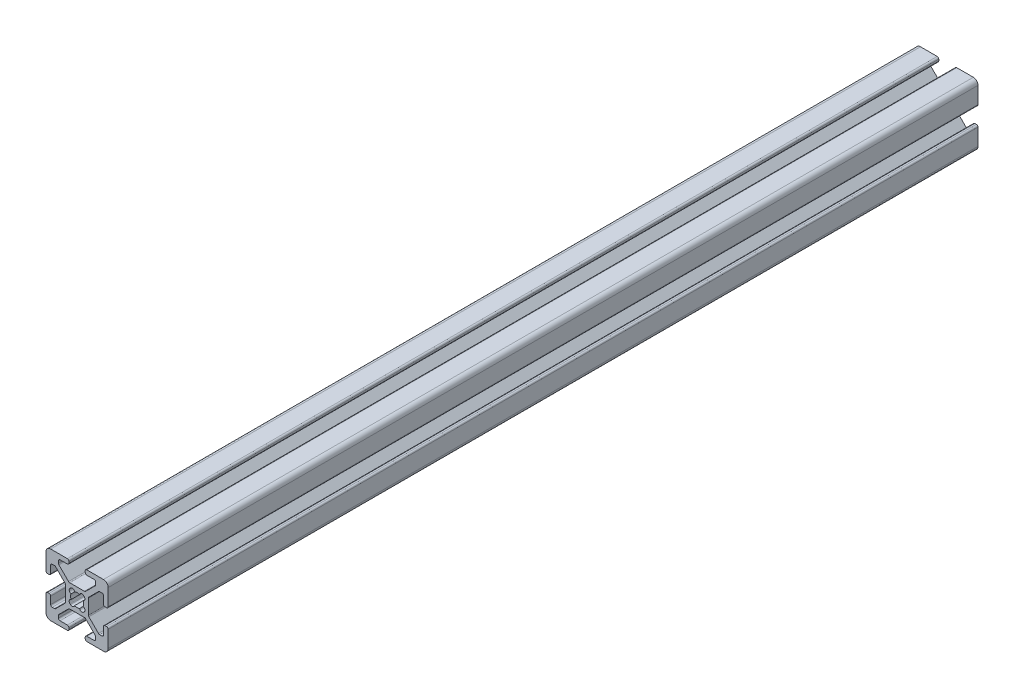
from build123d import *

# Parameters (mm, degrees)
BOSS_EXTRUDE1_DEPTH = 280


with BuildPart() as part:
    # Sketch1 → Boss-Extrude1 (new body)
    with BuildSketch(Plane.XY.offset(4000)):
        with BuildLine():
            Line((10, 3.138), (10, 8.5))
            ThreePointArc((10, 8.5), (9.560660172, 9.560660172), (8.5, 10))
            Line((8.5, 10), (3.138, 10))
            ThreePointArc((3.138, 10), (2.778789755, 9.851210245), (2.63, 9.492))
            Line((2.63, 9.492), (2.63, 9.008))
            ThreePointArc((2.63, 9.008), (2.778789755, 8.648789755), (3.138, 8.5))
            Line((3.138, 8.5), (5.487, 8.5))
            ThreePointArc((5.487, 8.5), (5.846210245, 8.351210245), (5.995, 7.992))
            Line((5.995, 7.992), (5.995, 7.266080661))
            ThreePointArc((5.995, 7.266080661), (5.956330803, 7.071677478), (5.846210245, 6.906870417))
            Line((5.846210245, 6.906870417), (2.743129583, 3.803789755))
            ThreePointArc((2.743129583, 3.803789755), (2.578322522, 3.693669197), (2.383919339, 3.655))
            Line((2.383919339, 3.655), (-2.383919339, 3.655))
            ThreePointArc((-2.383919339, 3.655), (-2.578322522, 3.693669197), (-2.743129583, 3.803789755))
            Line((-2.743129583, 3.803789755), (-5.846210245, 6.906870417))
            ThreePointArc((-5.846210245, 6.906870417), (-5.956330803, 7.071677478), (-5.995, 7.266080661))
            Line((-5.995, 7.266080661), (-5.995, 7.992))
            ThreePointArc((-5.995, 7.992), (-5.846210245, 8.351210245), (-5.487, 8.5))
            Line((-5.487, 8.5), (-3.138, 8.5))
            ThreePointArc((-3.138, 8.5), (-2.778789755, 8.648789755), (-2.63, 9.008))
            Line((-2.63, 9.008), (-2.63, 9.492))
            ThreePointArc((-2.63, 9.492), (-2.778789755, 9.851210245), (-3.138, 10))
            Line((-3.138, 10), (-8.5, 10))
            ThreePointArc((-8.5, 10), (-9.560660172, 9.560660172), (-10, 8.5))
            Line((-10, 8.5), (-10, 3.138))
            ThreePointArc((-10, 3.138), (-9.851210245, 2.778789755), (-9.492, 2.63))
            Line((-9.492, 2.63), (-9.008, 2.63))
            ThreePointArc((-9.008, 2.63), (-8.648789755, 2.778789755), (-8.5, 3.138))
            Line((-8.5, 3.138), (-8.5, 5.487))
            ThreePointArc((-8.5, 5.487), (-8.351210245, 5.846210245), (-7.992, 5.995))
            Line((-7.992, 5.995), (-7.266080661, 5.995))
            ThreePointArc((-7.266080661, 5.995), (-7.071677478, 5.956330803), (-6.906870417, 5.846210245))
            Line((-6.906870417, 5.846210245), (-3.803789755, 2.743129583))
            ThreePointArc((-3.803789755, 2.743129583), (-3.693669197, 2.578322522), (-3.655, 2.383919339))
            Line((-3.655, 2.383919339), (-3.655, -2.383919339))
            ThreePointArc((-3.655, -2.383919339), (-3.693669197, -2.578322522), (-3.803789755, -2.743129583))
            Line((-3.803789755, -2.743129583), (-6.906870417, -5.846210245))
            ThreePointArc((-6.906870417, -5.846210245), (-7.071677478, -5.956330803), (-7.266080661, -5.995))
            Line((-7.266080661, -5.995), (-7.992, -5.995))
            ThreePointArc((-7.992, -5.995), (-8.351210245, -5.846210245), (-8.5, -5.487))
            Line((-8.5, -5.487), (-8.5, -3.138))
            ThreePointArc((-8.5, -3.138), (-8.648789755, -2.778789755), (-9.008, -2.63))
            Line((-9.008, -2.63), (-9.492, -2.63))
            ThreePointArc((-9.492, -2.63), (-9.851210245, -2.778789755), (-10, -3.138))
            Line((-10, -3.138), (-10, -8.5))
            ThreePointArc((-10, -8.5), (-9.560660172, -9.560660172), (-8.5, -10))
            Line((-8.5, -10), (-3.138, -10))
            ThreePointArc((-3.138, -10), (-2.778789755, -9.851210245), (-2.63, -9.492))
            Line((-2.63, -9.492), (-2.63, -9.008))
            ThreePointArc((-2.63, -9.008), (-2.778789755, -8.648789755), (-3.138, -8.5))
            Line((-3.138, -8.5), (-5.487, -8.5))
            ThreePointArc((-5.487, -8.5), (-5.846210245, -8.351210245), (-5.995, -7.992))
            Line((-5.995, -7.992), (-5.995, -7.266080661))
            ThreePointArc((-5.995, -7.266080661), (-5.956330803, -7.071677478), (-5.846210245, -6.906870417))
            Line((-5.846210245, -6.906870417), (-2.743129583, -3.803789755))
            ThreePointArc((-2.743129583, -3.803789755), (-2.578322522, -3.693669197), (-2.383919339, -3.655))
            Line((-2.383919339, -3.655), (2.383919339, -3.655))
            ThreePointArc((2.383919339, -3.655), (2.578322522, -3.693669197), (2.743129583, -3.803789755))
            Line((2.743129583, -3.803789755), (5.846210245, -6.906870417))
            ThreePointArc((5.846210245, -6.906870417), (5.956330803, -7.071677478), (5.995, -7.266080661))
            Line((5.995, -7.266080661), (5.995, -7.992))
            ThreePointArc((5.995, -7.992), (5.846210245, -8.351210245), (5.487, -8.5))
            Line((5.487, -8.5), (3.138, -8.5))
            ThreePointArc((3.138, -8.5), (2.778789755, -8.648789755), (2.63, -9.008))
            Line((2.63, -9.008), (2.63, -9.492))
            ThreePointArc((2.63, -9.492), (2.778789755, -9.851210245), (3.138, -10))
            Line((3.138, -10), (8.5, -10))
            ThreePointArc((8.5, -10), (9.560660172, -9.560660172), (10, -8.5))
            Line((10, -8.5), (10, -3.138))
            ThreePointArc((10, -3.138), (9.851210245, -2.778789755), (9.492, -2.63))
            Line((9.492, -2.63), (9.008, -2.63))
            ThreePointArc((9.008, -2.63), (8.648789755, -2.778789755), (8.5, -3.138))
            Line((8.5, -3.138), (8.5, -5.487))
            ThreePointArc((8.5, -5.487), (8.351210245, -5.846210245), (7.992, -5.995))
            Line((7.992, -5.995), (7.266080661, -5.995))
            ThreePointArc((7.266080661, -5.995), (7.071677478, -5.956330803), (6.906870417, -5.846210245))
            Line((6.906870417, -5.846210245), (3.803789755, -2.743129583))
            ThreePointArc((3.803789755, -2.743129583), (3.693669197, -2.578322522), (3.655, -2.383919339))
            Line((3.655, -2.383919339), (3.655, 2.383919339))
            ThreePointArc((3.655, 2.383919339), (3.693669197, 2.578322522), (3.803789755, 2.743129583))
            Line((3.803789755, 2.743129583), (6.906870417, 5.846210245))
            ThreePointArc((6.906870417, 5.846210245), (7.071677478, 5.956330803), (7.266080661, 5.995))
            Line((7.266080661, 5.995), (7.992, 5.995))
            ThreePointArc((7.992, 5.995), (8.351210245, 5.846210245), (8.5, 5.487))
            Line((8.5, 5.487), (8.5, 3.138))
            ThreePointArc((8.5, 3.138), (8.648789755, 2.778789755), (9.008, 2.63))
            Line((9.008, 2.63), (9.492, 2.63))
            ThreePointArc((9.492, 2.63), (9.851210245, 2.778789755), (10, 3.138))
        make_face()
        with BuildLine():
            Line((-2.124900844, -2.304505966), (-2.304505966, -2.124900844))
            ThreePointArc((-2.304505966, -2.124900844), (-2.505938017, -1.356467811), (-1.935133506, -0.803976718))
            ThreePointArc((-1.935133506, -0.803976718), (-2.0955, 0), (-1.935133506, 0.803976718))
            ThreePointArc((-1.935133506, 0.803976718), (-2.505938017, 1.356467811), (-2.304505966, 2.124900844))
            Line((-2.304505966, 2.124900844), (-2.124900844, 2.304505966))
            ThreePointArc((-2.124900844, 2.304505966), (-1.356467811, 2.505938017), (-0.803976718, 1.935133506))
            ThreePointArc((-0.803976718, 1.935133506), (0, 2.0955), (0.803976718, 1.935133506))
            ThreePointArc((0.803976718, 1.935133506), (1.356467811, 2.505938017), (2.124900844, 2.304505966))
            Line((2.124900844, 2.304505966), (2.304505966, 2.124900844))
            ThreePointArc((2.304505966, 2.124900844), (2.505938017, 1.356467811), (1.935133506, 0.803976718))
            ThreePointArc((1.935133506, 0.803976718), (2.0955, 0), (1.935133506, -0.803976718))
            ThreePointArc((1.935133506, -0.803976718), (2.505938017, -1.356467811), (2.304505966, -2.124900844))
            Line((2.304505966, -2.124900844), (2.124900844, -2.304505966))
            ThreePointArc((2.124900844, -2.304505966), (1.356467811, -2.505938017), (0.803976718, -1.935133506))
            ThreePointArc((0.803976718, -1.935133506), (0, -2.0955), (-0.803976718, -1.935133506))
            ThreePointArc((-0.803976718, -1.935133506), (-1.356467811, -2.505938017), (-2.124900844, -2.304505966))
        make_face(mode=Mode.SUBTRACT)
    extrude(amount=-BOSS_EXTRUDE1_DEPTH)


solid = part.part
